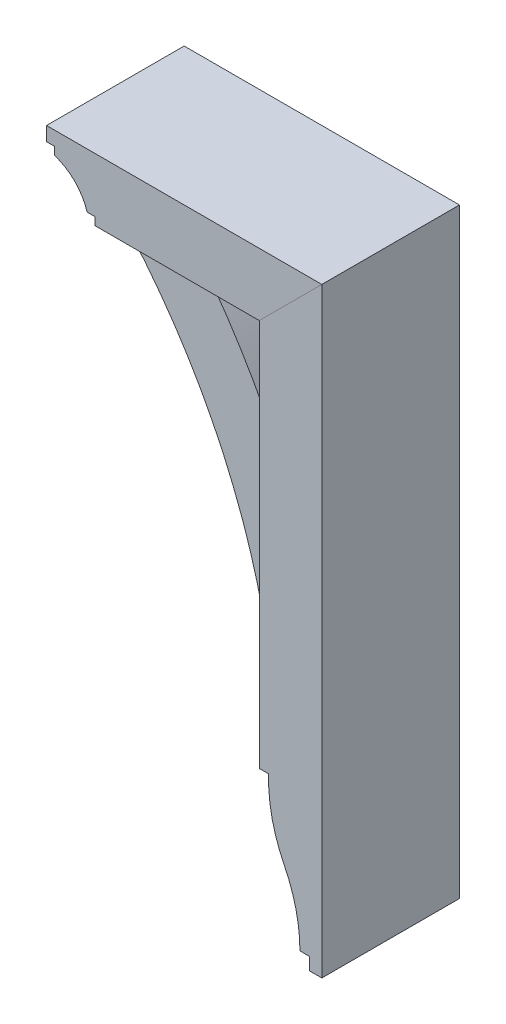
from build123d import *

# Parameters (mm, degrees)
BOSS_EXTRUDE1_DEPTH = 69.85
BOSS_EXTRUDE2_DEPTH = 44.45
BOSS_EXTRUDE3_DEPTH = 69.85


with BuildPart() as part:
    # Sketch1 → Boss-Extrude1 (new body, symmetric)
    with BuildSketch(Plane.XY):
        with BuildLine():
            Line((26.218723016, 251.46), (26.218723016, 259.3975))
            Line((26.218723016, 259.3975), (18.281223016, 259.3975))
            Line((18.281223016, 259.3975), (18.281223016, 273.685))
            Line((18.281223016, 273.685), (297.681223016, 273.685))
            Line((297.681223016, 273.685), (234.181223016, 210.185))
            Line((234.181223016, 210.185), (67.493723016, 210.185))
            Line((67.493723016, 210.185), (67.493723016, 218.1225))
            Line((67.493723016, 218.1225), (59.556223016, 218.1225))
            ThreePointArc((59.556223016, 218.1225), (46.995199198, 238.898976183), (26.218723016, 251.46))
        make_face()
    extrude(amount=BOSS_EXTRUDE1_DEPTH, both=True)


with BuildPart() as body_2:
    # Sketch1_3 → Boss-Extrude2 (new body, symmetric)
    with BuildSketch(Plane.XY):
        with BuildLine():
            ThreePointArc((234.181223016, 65.7225), (195.832286344, 140.632128239), (148.456223016, 210.185))
            Line((148.456223016, 210.185), (77.018723016, 210.185))
            Line((77.018723016, 210.185), (77.018723016, 197.485))
            ThreePointArc((77.018723016, 197.485), (172.381558372, 49.259871337), (221.481223016, -120.015))
            Line((221.481223016, -120.015), (234.181223016, -120.015))
            Line((234.181223016, -120.015), (234.181223016, 65.7225))
        make_face()
    extrude(amount=BOSS_EXTRUDE2_DEPTH, both=True)


with BuildPart() as body_3:
    # Sketch1_4 → Boss-Extrude3 (new body, symmetric)
    with BuildSketch(Plane.XY):
        with BuildLine():
            Line((297.681223016, -335.915), (297.681223016, 273.685))
            Line((297.681223016, 273.685), (234.181223016, 210.185))
            Line((234.181223016, 210.185), (234.181223016, -183.515))
            Line((234.181223016, -183.515), (243.706223016, -183.515))
            ThreePointArc((243.706223016, -183.515), (247.123793252, -220.636316239), (259.542371159, -255.785296713))
            ThreePointArc((259.542371159, -255.785296713), (271.423852, -288.573927679), (275.456223016, -323.215))
            Line((275.456223016, -323.215), (284.981223016, -323.215))
            Line((284.981223016, -323.215), (284.981223016, -335.915))
            Line((284.981223016, -335.915), (297.681223016, -335.915))
        make_face()
    extrude(amount=BOSS_EXTRUDE3_DEPTH, both=True)


solid = Compound([part.part, body_2.part, body_3.part])
